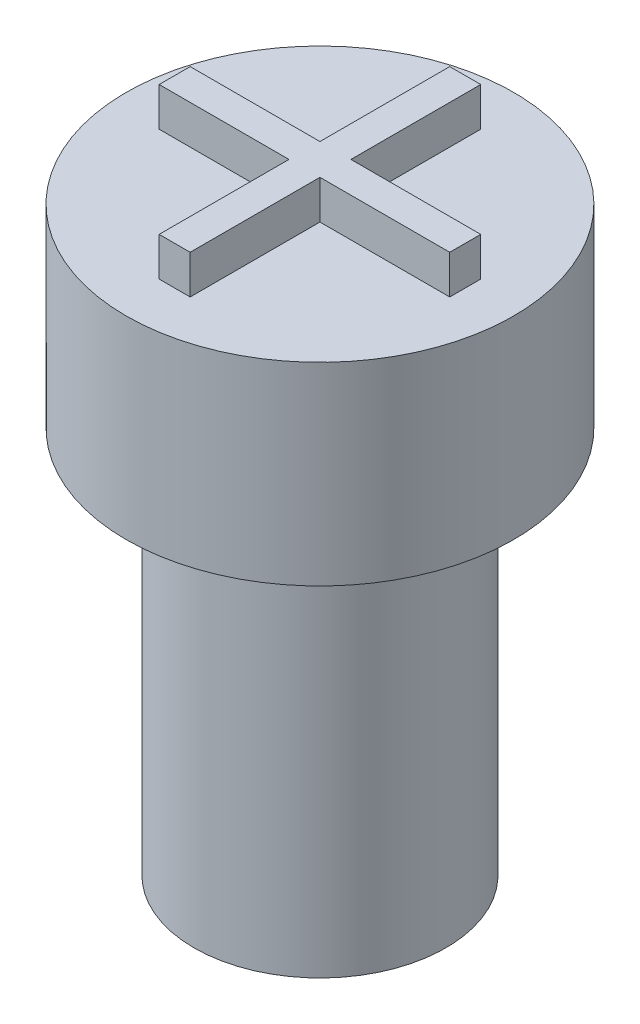
from build123d import *

# Parameters (mm, degrees)
SKETCH1_R           = 3.25
BOSS_EXTRUDE1_DEPTH = 10
SKETCH2_R           = 1.75
CUT_EXTRUDE1_DEPTH  = 2.5
SKETCH6_R           = 5
BOSS_EXTRUDE2_DEPTH = 5
BOSS_EXTRUDE3_DEPTH = 1


with BuildPart() as part:
    # Sketch1 → Boss-Extrude1 (new body)
    with BuildSketch(Plane(origin=(0, 0, 0), x_dir=(1, 0, 0), z_dir=(0, 1, 0))):
        Circle(SKETCH1_R)
    extrude(amount=BOSS_EXTRUDE1_DEPTH)

    # Sketch2 → Cut-Extrude1 (cut)
    with BuildSketch(Plane.XZ):
        Circle(SKETCH2_R)
    extrude(amount=-CUT_EXTRUDE1_DEPTH, mode=Mode.SUBTRACT)

    # Sketch6 → Boss-Extrude2 (add)
    with BuildSketch(Plane(origin=(0, 10, 0), x_dir=(1, 0, 0), z_dir=(0, 1, 0))):
        Circle(SKETCH6_R)
    extrude(amount=BOSS_EXTRUDE2_DEPTH)

    # Sketch8 → Boss-Extrude3 (add)
    with BuildSketch(Plane(origin=(0, 15, 0), x_dir=(1, 0, 0), z_dir=(0, 1, 0))):
        Polygon((0.4, 3.75), (-0.4, 3.75), (-0.4, 0.4), (-3.75, 0.4), (-3.75, -0.4), (-0.4, -0.4), (-0.4, -3.75), (0.4, -3.75), (0.4, -0.4), (3.75, -0.4), (3.75, 0.4), (0.4, 0.4), align=None)
    extrude(amount=BOSS_EXTRUDE3_DEPTH)


solid = part.part
